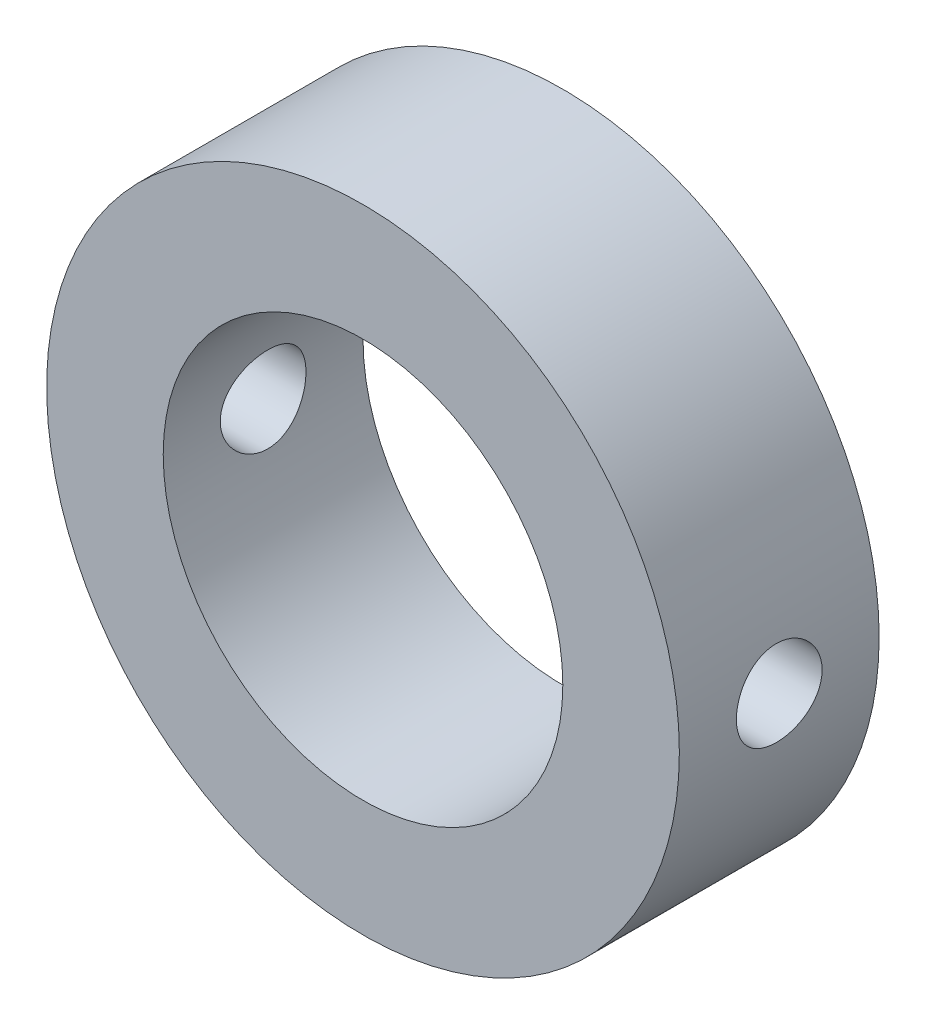
from build123d import *

# Parameters (mm, degrees)
SKETCH1_R           = 19
SKETCH1_R_2         = 12
BOSS_EXTRUDE2_DEPTH = 6
SKETCH3_R           = 2.574867252
CUT_EXTRUDE1_DEPTH  = 36


with BuildPart() as part:
    # Sketch1 → Boss-Extrude2 (new body, symmetric)
    with BuildSketch(Plane.XY):
        Circle(SKETCH1_R)
        Circle(SKETCH1_R_2, mode=Mode.SUBTRACT)
    extrude(amount=BOSS_EXTRUDE2_DEPTH, both=True)

    # Sketch3 → Cut-Extrude1 (cut, symmetric)
    with BuildSketch(Plane(origin=(0, 0, 0), x_dir=(0, 0, -1), z_dir=(1, 0, 0))):
        Circle(SKETCH3_R)
    extrude(amount=CUT_EXTRUDE1_DEPTH, both=True, mode=Mode.SUBTRACT)


solid = part.part
